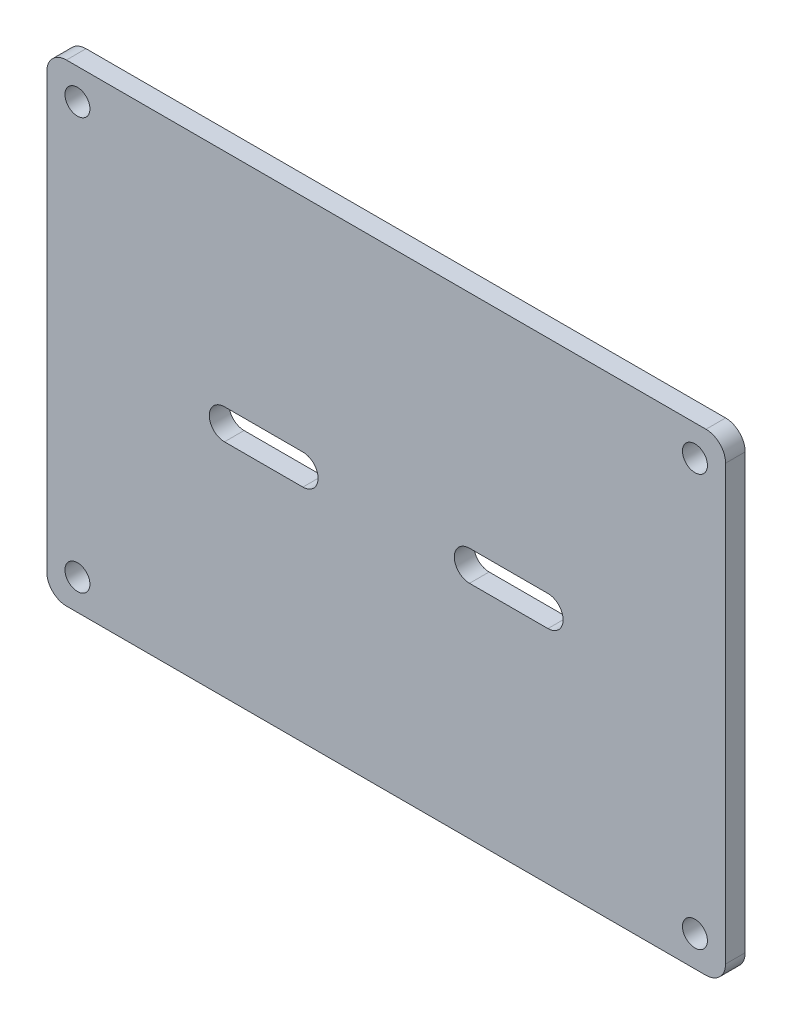
from build123d import *

# Parameters (mm, degrees)
SKETCH_1_W      = 69.25
SKETCH_1_H      = 48.25
SKETCH_1_R      = 1.275
EXTRUDE_1_DEPTH = 2
FILLET_1_R      = 2


with BuildPart() as part:
    # 草图1 → 凸台-拉伸1 (new body)
    with BuildSketch(Plane.XY):
        Rectangle(SKETCH_1_W, SKETCH_1_H)
        with Locations((-31.5, 21)):
            Circle(SKETCH_1_R, mode=Mode.SUBTRACT)
        with Locations((31.5, 21)):
            Circle(SKETCH_1_R, mode=Mode.SUBTRACT)
        with Locations((-31.5, -21)):
            Circle(SKETCH_1_R, mode=Mode.SUBTRACT)
        with Locations((31.5, -21)):
            Circle(SKETCH_1_R, mode=Mode.SUBTRACT)
        with BuildLine():
            Line((-16.5, 1.55), (-8.5, 1.55))
            ThreePointArc((-8.5, 1.55), (-6.95, 0), (-8.5, -1.55))
            Line((-8.5, -1.55), (-16.5, -1.55))
            ThreePointArc((-16.5, -1.55), (-18.05, 0), (-16.5, 1.55))
        make_face(mode=Mode.SUBTRACT)
        with BuildLine():
            Line((16.5, -1.55), (8.5, -1.55))
            ThreePointArc((8.5, -1.55), (6.95, 0), (8.5, 1.55))
            Line((8.5, 1.55), (16.5, 1.55))
            ThreePointArc((16.5, 1.55), (18.05, 0), (16.5, -1.55))
        make_face(mode=Mode.SUBTRACT)
    extrude(amount=EXTRUDE_1_DEPTH)

    # 圆角1
    fillet_1_edges = [part.edges().sort_by_distance(p)[0] for p in [
        (-34.625, 24.125, 1),
        (34.625, 24.125, 1),
        (34.625, -24.125, 1),
        (-34.625, -24.125, 1),
    ]]
    fillet(fillet_1_edges, radius=FILLET_1_R)


solid = part.part
